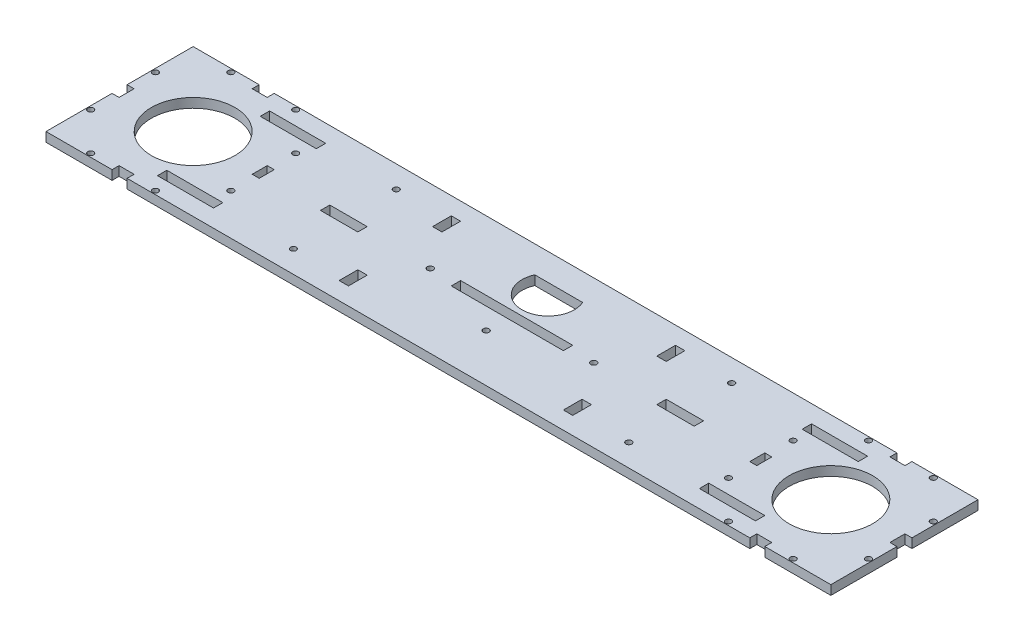
from build123d import *

# Parameters (mm, degrees)
SKETCH1_W           = 533.4
SKETCH1_H           = 100
SKETCH1_R           = 1.9842329
SKETCH1_R_2         = 2.018120645
SKETCH1_R_3         = 2.032
SKETCH1_W_2         = 76.2
SKETCH1_H_2         = 6.35
SKETCH1_W_3         = 25.4
SKETCH1_W_4         = 6.35
SKETCH1_H_3         = 12.7
SKETCH1_W_5         = 38.1
BOSS_EXTRUDE1_DEPTH = 6.35
SKETCH2_R           = 1.984375
SKETCH2_R_2         = 28.360038464
SKETCH2_W           = 4.7625
SKETCH2_H           = 10.2
SKETCH2_W_2         = 10.2
SKETCH2_H_2         = 4.7625
CUT_EXTRUDE2_DEPTH  = 6.35


with BuildPart() as part:
    # Sketch1 → Boss-Extrude1 (new body)
    with BuildSketch(Plane(origin=(0, 0, 0), x_dir=(1, 0, 0), z_dir=(0, 1, 0))):
        Rectangle(SKETCH1_W, SKETCH1_H)
        with Locations((-113.583722144, -34.925)):
            Circle(SKETCH1_R, mode=Mode.SUBTRACT)
        with Locations((114.309932521, 34.925)):
            Circle(SKETCH1_R_2, mode=Mode.SUBTRACT)
        with Locations((114.309932521, -34.925)):
            Circle(SKETCH1_R_2, mode=Mode.SUBTRACT)
        with Locations((-113.583722144, 34.925)):
            Circle(SKETCH1_R, mode=Mode.SUBTRACT)
        with Locations((-55.5625, 0)):
            Circle(SKETCH1_R_3, mode=Mode.SUBTRACT)
        with Locations((55.5625, 0)):
            Circle(SKETCH1_R_3, mode=Mode.SUBTRACT)
        with Locations((0, -17.5895)):
            Circle(SKETCH1_R_3, mode=Mode.SUBTRACT)
        Rectangle(SKETCH1_W_2, SKETCH1_H_2, mode=Mode.SUBTRACT)
        with Locations((114.3, 0)):
            Rectangle(SKETCH1_W_3, SKETCH1_H_2, mode=Mode.SUBTRACT)
        with Locations((-114.3, 0)):
            Rectangle(SKETCH1_W_3, SKETCH1_H_2, mode=Mode.SUBTRACT)
        with Locations((76.2, -31.75)):
            Rectangle(SKETCH1_W_4, SKETCH1_H_3, mode=Mode.SUBTRACT)
        with Locations((-76.2, -31.75)):
            Rectangle(SKETCH1_W_4, SKETCH1_H_3, mode=Mode.SUBTRACT)
        with Locations((76.2, 31.75)):
            Rectangle(SKETCH1_W_4, SKETCH1_H_3, mode=Mode.SUBTRACT)
        with Locations((-76.2, 31.75)):
            Rectangle(SKETCH1_W_4, SKETCH1_H_3, mode=Mode.SUBTRACT)
        with Locations((184.513105188, -34.925)):
            Rectangle(SKETCH1_W_5, SKETCH1_H_2, mode=Mode.SUBTRACT)
        with Locations((-183.786894812, 34.925)):
            Rectangle(SKETCH1_W_5, SKETCH1_H_2, mode=Mode.SUBTRACT)
        with Locations((184.513105188, 34.925)):
            Rectangle(SKETCH1_W_5, SKETCH1_H_2, mode=Mode.SUBTRACT)
        with Locations((-183.786894812, -34.925)):
            Rectangle(SKETCH1_W_5, SKETCH1_H_2, mode=Mode.SUBTRACT)
        with BuildLine():
            Line((-16.279001812, 31.75), (16.279001812, 31.75))
            ThreePointArc((16.279001812, 31.75), (0, 6.82), (-16.279001812, 31.75))
        make_face(mode=Mode.SUBTRACT)
    extrude(amount=BOSS_EXTRUDE1_DEPTH)

    # Sketch2 → Cut-Extrude2 (cut)
    with BuildSketch(Plane(origin=(0, 0, 0), x_dir=(1, 0, 0), z_dir=(0, 1, 0))):
        with Locations((-169.08125, 22)):
            Circle(SKETCH2_R)
        with Locations((-169.08125, -22)):
            Circle(SKETCH2_R)
        with Locations((-194.7, -47.61875)):
            Circle(SKETCH2_R)
        with Locations((-238.7, -47.61875)):
            Circle(SKETCH2_R)
        with Locations((-264.31875, -22)):
            Circle(SKETCH2_R)
        with Locations((-264.31875, 22)):
            Circle(SKETCH2_R)
        with Locations((-194.7, 47.61875)):
            Circle(SKETCH2_R)
        with Locations((-238.7, 47.61875)):
            Circle(SKETCH2_R)
        with Locations((-216.7, 0)):
            Circle(SKETCH2_R_2)
        with Locations((216.7, 0)):
            Circle(SKETCH2_R_2)
        with Locations((238.7, 47.61875)):
            Circle(SKETCH2_R)
        with Locations((194.7, 47.61875)):
            Circle(SKETCH2_R)
        with Locations((264.31875, 22)):
            Circle(SKETCH2_R)
        with Locations((264.31875, -22)):
            Circle(SKETCH2_R)
        with Locations((238.7, -47.61875)):
            Circle(SKETCH2_R)
        with Locations((194.7, -47.61875)):
            Circle(SKETCH2_R)
        with Locations((169.08125, -22)):
            Circle(SKETCH2_R)
        with Locations((169.08125, 22)):
            Circle(SKETCH2_R)
        with Locations((-169.08125, 0)):
            Rectangle(SKETCH2_W, SKETCH2_H)
        with Locations((-264.31875, 0)):
            Rectangle(SKETCH2_W, SKETCH2_H)
        with Locations((-216.7, 47.61875)):
            Rectangle(SKETCH2_W_2, SKETCH2_H_2)
        with Locations((-216.7, -47.61875)):
            Rectangle(SKETCH2_W_2, SKETCH2_H_2)
        with Locations((216.7, -47.61875)):
            Rectangle(SKETCH2_W_2, SKETCH2_H_2)
        with Locations((216.7, 47.61875)):
            Rectangle(SKETCH2_W_2, SKETCH2_H_2)
        with Locations((264.31875, 0)):
            Rectangle(SKETCH2_W, SKETCH2_H)
        with Locations((169.08125, 0)):
            Rectangle(SKETCH2_W, SKETCH2_H)
    extrude(amount=CUT_EXTRUDE2_DEPTH, mode=Mode.SUBTRACT)


solid = part.part
